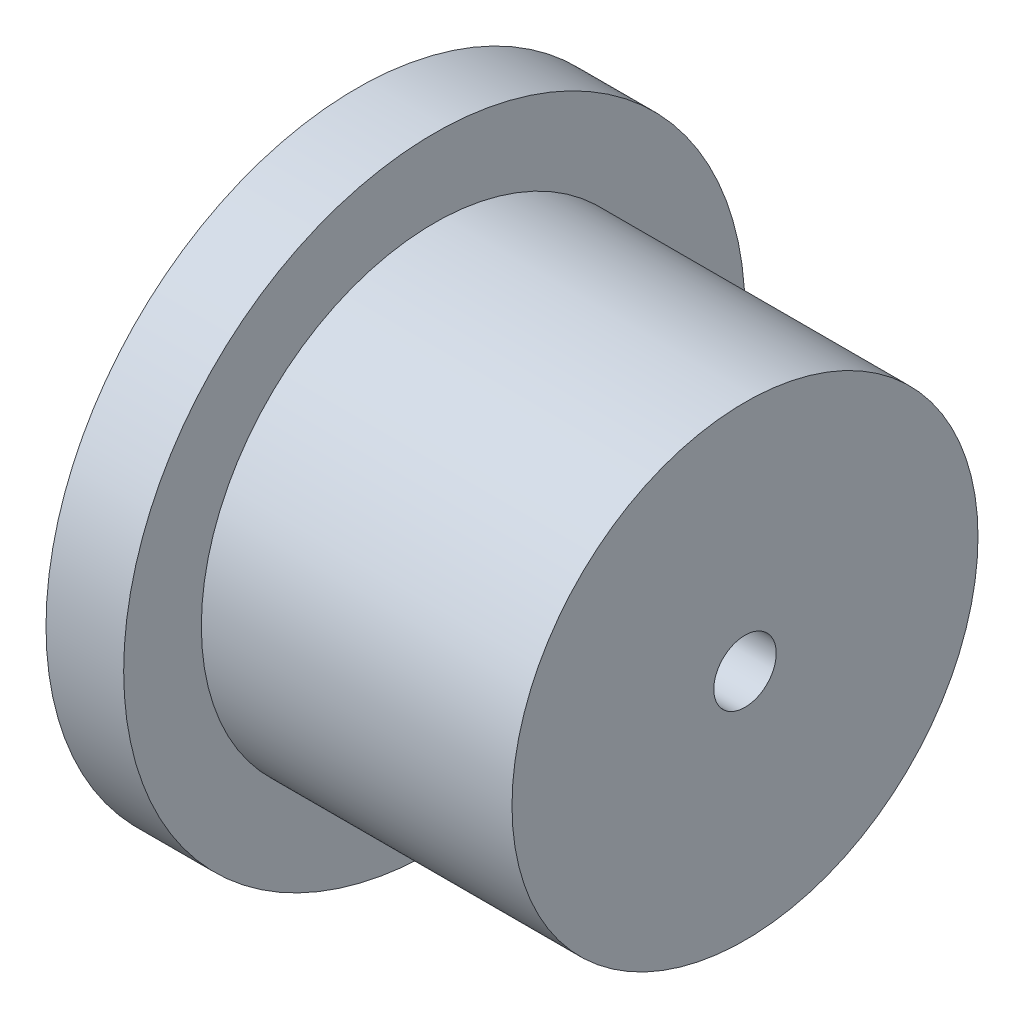
from build123d import *

# Parameters (mm, degrees)
F_1_4_20_TAPPED_HOLE1_D           = 5.1054
F_1_4_20_TAPPED_HOLE1_CSINK_D     = 7.62
F_1_4_20_TAPPED_HOLE1_CSINK_ANGLE = 100


with BuildPart() as part:
    # Sketch1 → Revolve1 (revolve)
    with BuildSketch(Plane.XY):
        Polygon((0, 0), (0, -19.05), (-25.4, -19.05), (-25.4, -25.4), (-31.75, -25.4), (-31.75, 0), align=None)
    revolve(axis=Axis((-45.965152255, 0, 0), (1, 0, 0)))

    # 1/4-20 Tapped Hole1 (through all)
    with Locations(Plane.ZY.offset(31.75)):
        with Locations((0, 0)):
            CounterSinkHole(F_1_4_20_TAPPED_HOLE1_D / 2, F_1_4_20_TAPPED_HOLE1_CSINK_D / 2, counter_sink_angle=F_1_4_20_TAPPED_HOLE1_CSINK_ANGLE)


solid = part.part
